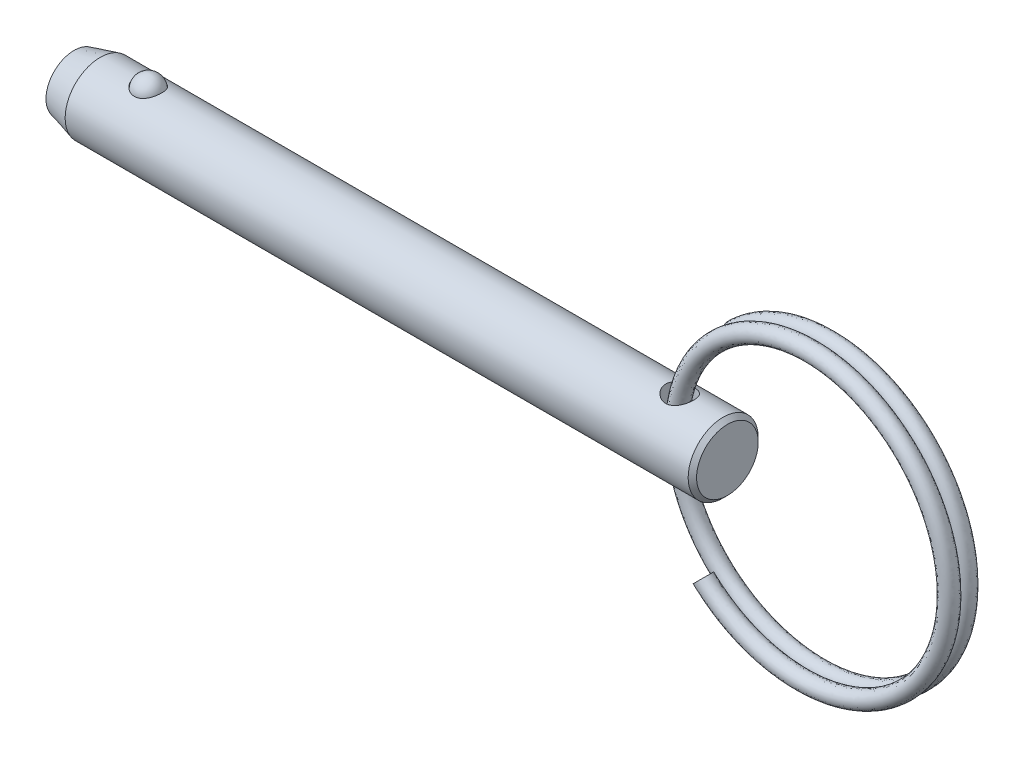
from build123d import *

# Parameters (mm, degrees)
SKETCH4_W          = 1.27
SKETCH4_H          = 6.35
SWEEP1_PITCH       = 1.5494
SWEEP1_HEIGHT      = 1.355725
SWEEP1_RADIUS      = 13.462
SKETCH6_R          = 0.762
SWEEP2_PITCH       = 1.5494
SWEEP2_HEIGHT      = 1.355725
SWEEP2_RADIUS      = 13.462
SWEEP2_START_ANGLE = -180
SKETCH6_2_R        = 0.762


with BuildPart() as part:
    # Sketch1 → Revolve1 (revolve)
    with BuildSketch(Plane.XY):
        Polygon((29.6164, 2.794), (29.2354, 3.175), (-27.246547737, 3.175), (-29.6164, 2.54), (-29.6164, 0), (29.6164, 0), align=None)
    revolve(axis=Axis((29.6164, 0, 0), (1, 0, 0)))

    # Sketch2 → Cut-Revolve1 (revolve, cut)
    with BuildSketch(Plane.XY):
        with BuildLine():
            Line((-21.624582051, 2.8575), (-24.139182051, 2.8575))
            ThreePointArc((-24.139182051, 2.8575), (-22.881882051, 4.1148), (-21.624582051, 2.8575))
        make_face()
    revolve(axis=Axis((-21.624582051, 2.8575, 0), (1, 0, 0)), mode=Mode.SUBTRACT)

    # Sketch4 → Cut-Revolve2 (revolve, cut)
    with BuildSketch(Plane.XY):
        with Locations((25.9334, 0)):
            Rectangle(SKETCH4_W, SKETCH4_H)
    revolve(axis=Axis((25.2984, -3.175, 0), (0, 1, 0)), mode=Mode.SUBTRACT)


with BuildPart() as body_2:
    # Sketch3 → Revolve2 (revolve)
    with BuildSketch(Plane.XY):
        with BuildLine():
            Line((-21.649982051, 2.8575), (-24.113782051, 2.8575))
            ThreePointArc((-24.113782051, 2.8575), (-22.881882051, 4.0894), (-21.649982051, 2.8575))
        make_face()
    revolve(axis=Axis((-21.649982051, 2.8575, 0), (1, 0, 0)))


with BuildPart() as body_3:
    # Sweep1: sweep along a helix
    with BuildLine() as sweep1_path:
        Helix(SWEEP1_PITCH, SWEEP1_HEIGHT, SWEEP1_RADIUS, center=(37.783425091, 0, 0), direction=(0, 0, -1), lefthand=True)
    # Sketch6 → Sweep1 (sweep)
    with BuildSketch(Plane(origin=(114.003847968, 0, 0), x_dir=(0, 0, -1), z_dir=(0, 1, 0))):
        with Locations((0, 88.920422877)):
            Circle(SKETCH6_R)
    sweep(path=sweep1_path.line, is_frenet=True)

    # Sweep2: sweep along a helix
    with BuildLine() as sweep2_path:
        add(Helix(SWEEP2_PITCH, SWEEP2_HEIGHT, SWEEP2_RADIUS, center=(37.783425091, 0, 0), direction=(0, 0, 1), lefthand=True, mode=Mode.PRIVATE).rotate(Axis((37.783425091, 0, 0), (0, 0, 1)), SWEEP2_START_ANGLE))
    # Sketch6_2 → Sweep2 (sweep)
    with BuildSketch(Plane(origin=(114.003847968, 0, 0), x_dir=(0, 0, -1), z_dir=(0, 1, 0))):
        with Locations((0, 88.920422877)):
            Circle(SKETCH6_2_R)
    sweep(path=sweep2_path.line, is_frenet=True)


solid = Compound([part.part, body_2.part, body_3.part])
